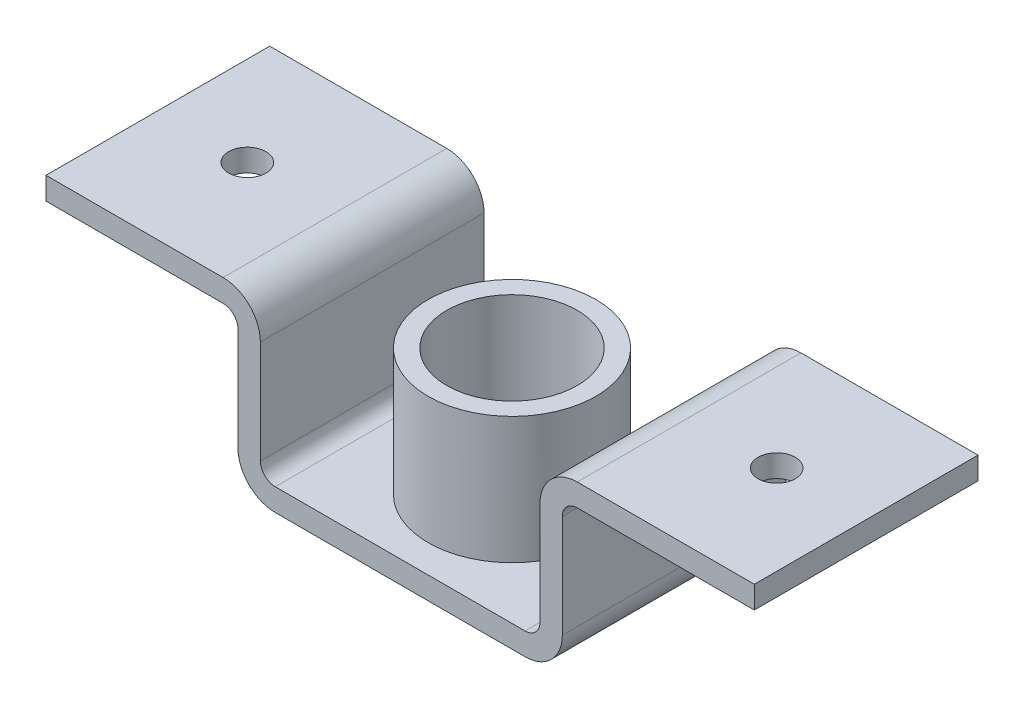
from build123d import *

# Parameters (mm, degrees)
BOSS_EXTRUDE1_DEPTH = 300
SKETCH3_R           = 112.5
SKETCH3_R_2         = 87.5
BOSS_EXTRUDE2_DEPTH = 170
SKETCH4_R           = 37.5
CUT_EXTRUDE1_DEPTH  = 170
SKETCH5_R           = 25
CUT_EXTRUDE2_DEPTH  = 170


with BuildPart() as part:
    # Sketch1 → Boss-Extrude1 (new body)
    with BuildSketch(Plane.XY):
        with BuildLine():
            Line((167.5, 0), (-167.5, 0))
            ThreePointArc((-167.5, 0), (-202.855339059, 14.644660941), (-217.5, 50))
            Line((-217.5, 50), (-217.5, 188))
            ThreePointArc((-217.5, 188), (-223.357864376, 202.142135624), (-237.5, 208))
            Line((-237.5, 208), (-475, 208))
            Line((-475, 208), (-475, 238))
            Line((-475, 238), (-237.5, 238))
            ThreePointArc((-237.5, 238), (-202.144660941, 223.355339059), (-187.5, 188))
            Line((-187.5, 188), (-187.5, 50))
            ThreePointArc((-187.5, 50), (-181.642135624, 35.857864376), (-167.5, 30))
            Line((-167.5, 30), (167.5, 30))
            ThreePointArc((167.5, 30), (181.642135624, 35.857864376), (187.5, 50))
            Line((187.5, 50), (187.5, 188))
            ThreePointArc((187.5, 188), (202.144660941, 223.355339059), (237.5, 238))
            Line((237.5, 238), (475, 238))
            Line((475, 238), (475, 208))
            Line((475, 208), (237.5, 208))
            ThreePointArc((237.5, 208), (223.357864376, 202.142135624), (217.5, 188))
            Line((217.5, 188), (217.5, 50))
            ThreePointArc((217.5, 50), (202.855339059, 14.644660941), (167.5, 0))
        make_face()
    extrude(amount=BOSS_EXTRUDE1_DEPTH)

    # Sketch3 → Boss-Extrude2 (add)
    with BuildSketch(Plane(origin=(0, 30, 0), x_dir=(1, 0, 0), z_dir=(0, 1, 0))):
        with Locations((0, -150)):
            Circle(SKETCH3_R)
        with Locations((0, -150)):
            Circle(SKETCH3_R_2, mode=Mode.SUBTRACT)
    extrude(amount=BOSS_EXTRUDE2_DEPTH)

    # Sketch4 → Cut-Extrude1 (cut)
    with BuildSketch(Plane(origin=(0, 30, 0), x_dir=(1, 0, 0), z_dir=(0, 1, 0))):
        with Locations((0, -150)):
            Circle(SKETCH4_R)
    extrude(amount=-CUT_EXTRUDE1_DEPTH, mode=Mode.SUBTRACT)

    # Sketch5 → Cut-Extrude2 (cut)
    with BuildSketch(Plane(origin=(0, 238, 0), x_dir=(1, 0, 0), z_dir=(0, 1, 0))):
        with Locations((355, -150)):
            Circle(SKETCH5_R)
        with Locations((-355, -150)):
            Circle(SKETCH5_R)
    extrude(amount=-CUT_EXTRUDE2_DEPTH, mode=Mode.SUBTRACT)


solid = part.part
